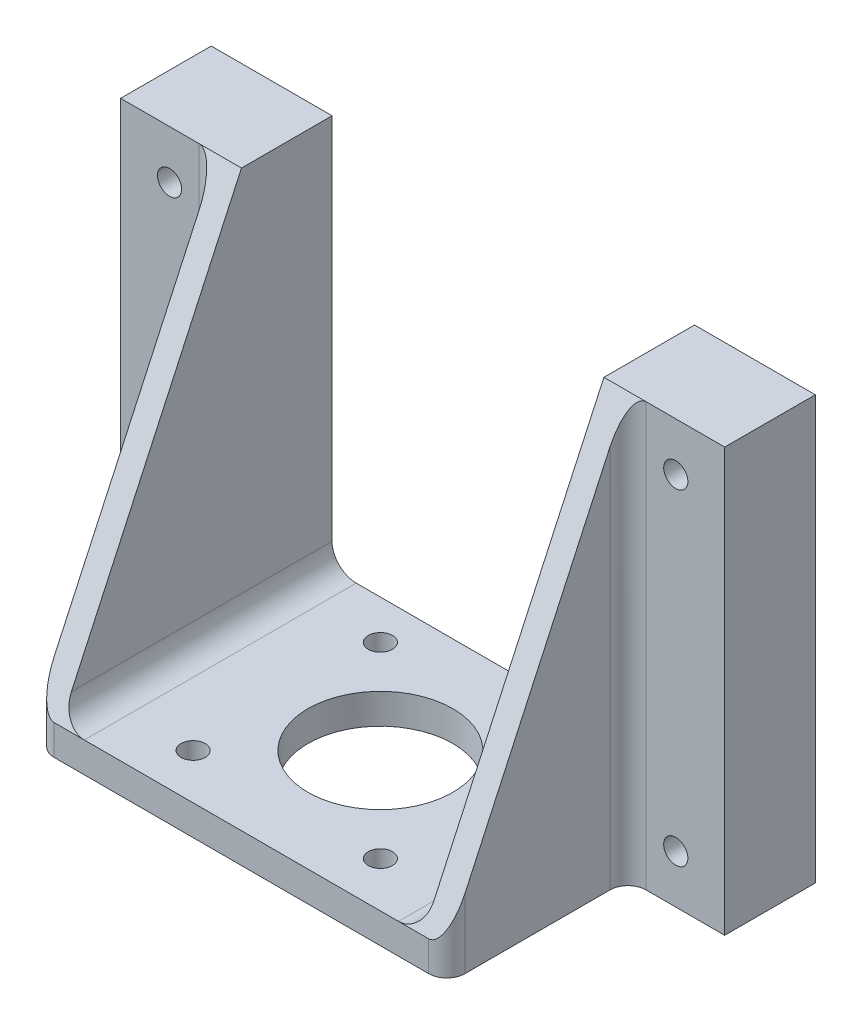
from build123d import *

# Parameters (mm, degrees)
SKETCH_5_W          = 100
SKETCH_5_H          = 70
SKETCH_5_R          = 2
EXTRUDE_10_DEPTH    = 0.0001
SKETCH_6_W          = 60
SKETCH_6_H          = 5
EXTRUDE_11_DEPTH    = 45
SKETCH_7_W          = 4
SKETCH_7_H          = 70
EXTRUDE_12_DEPTH    = 45
CUT_EXTRUDE_1_DEPTH = 76
SKETCH_16_W         = 16
SKETCH_16_H         = 70
EXTRUDE_16_DEPTH    = 15
SKETCH_5_3_R        = 2
CUT_EXTRUDE_2_DEPTH = 49
SKETCH_17_R         = 2
SKETCH_17_R_2       = 12
CUT_EXTRUDE_5_DEPTH = 98.082485547
FILLET_1_R          = 3
SKETCH_18_W         = 60
SKETCH_18_H         = 65
CUT_EXTRUDE_6_DEPTH = 76.828754441
FILLET_2_R          = 4


with BuildPart() as part:
    # 草图5 → 凸台-拉伸10 (new body)
    with BuildSketch(Plane.XY):
        Rectangle(SKETCH_5_W, SKETCH_5_H)
        with Locations((-41.9, 27)):
            Circle(SKETCH_5_R, mode=Mode.SUBTRACT)
        with Locations((-41.9, -27)):
            Circle(SKETCH_5_R, mode=Mode.SUBTRACT)
        with Locations((41.9, -27)):
            Circle(SKETCH_5_R, mode=Mode.SUBTRACT)
        with Locations((41.9, 27)):
            Circle(SKETCH_5_R, mode=Mode.SUBTRACT)
    extrude(amount=EXTRUDE_10_DEPTH)

    # 草图6 → 凸台-拉伸11 (add)
    with BuildSketch(Plane.XY.offset(0.0001)):
        with Locations((0, -32.5)):
            Rectangle(SKETCH_6_W, SKETCH_6_H)
    extrude(amount=EXTRUDE_11_DEPTH)

    # 草图7 → 凸台-拉伸12 (add)
    with BuildSketch(Plane.XY.offset(0.0001)):
        with Locations((-32, 0)):
            Rectangle(SKETCH_7_W, SKETCH_7_H)
        with Locations((32, 0)):
            Rectangle(SKETCH_7_W, SKETCH_7_H)
    extrude(amount=EXTRUDE_12_DEPTH)

    # 草图8 → 切除-拉伸1 (cut)
    with BuildSketch(Plane.ZY.offset(34)):
        Polygon((45.0001, -30), (15.0001, 35), (45.0001, 35), align=None)
    extrude(amount=-CUT_EXTRUDE_1_DEPTH, mode=Mode.SUBTRACT)

    # 草图16 → 凸台-拉伸16 (add)
    with BuildSketch(Plane.XY.offset(0.0001)):
        with Locations((42, 0)):
            Rectangle(SKETCH_16_W, SKETCH_16_H)
        with Locations((-42, 0)):
            Rectangle(SKETCH_16_W, SKETCH_16_H)
    extrude(amount=EXTRUDE_16_DEPTH)

    # 草图5<3> → 切除-拉伸2 (cut)
    with BuildSketch(Plane.XY):
        with Locations((-41.9, 27)):
            Circle(SKETCH_5_3_R)
        with Locations((-41.9, -27)):
            Circle(SKETCH_5_3_R)
        with Locations((41.9, 27)):
            Circle(SKETCH_5_3_R)
        with Locations((41.9, -27)):
            Circle(SKETCH_5_3_R)
    extrude(amount=CUT_EXTRUDE_2_DEPTH, mode=Mode.SUBTRACT)

    # 草图17 → 切除-拉伸5 (cut, through all)
    with BuildSketch(Plane.XZ.offset(35)):
        with Locations((-15.5, 37.5)):
            Circle(SKETCH_17_R)
        with Locations((0, 22)):
            Circle(SKETCH_17_R_2)
        with Locations((15.5, 37.5)):
            Circle(SKETCH_17_R)
        with Locations((-15.5, 6.5)):
            Circle(SKETCH_17_R)
        with Locations((15.5, 6.5)):
            Circle(SKETCH_17_R)
    extrude(amount=-CUT_EXTRUDE_5_DEPTH, mode=Mode.SUBTRACT)

    # 圆角1
    fillet_1_edges = [part.edges().sort_by_distance(p)[0] for p in [
        (34, 0, 15.0001),
        (-34, 0, 15.0001),
        (-34, -32.5, 45.0001),
        (34, -32.5, 45.0001),
    ]]
    fillet(fillet_1_edges, radius=FILLET_1_R)

    # 草图18 → 切除-拉伸6 (cut, through all)
    with BuildSketch(Plane.XY.offset(0.0001)):
        with Locations((0, 2.5)):
            Rectangle(SKETCH_18_W, SKETCH_18_H)
    extrude(amount=-CUT_EXTRUDE_6_DEPTH, mode=Mode.SUBTRACT)

    # 圆角2
    fillet_2_edges = [part.edges().sort_by_distance(p)[0] for p in [
        (-30, -30, 22.50005),
        (30, -30, 22.50005),
    ]]
    fillet(fillet_2_edges, radius=FILLET_2_R)


solid = part.part
